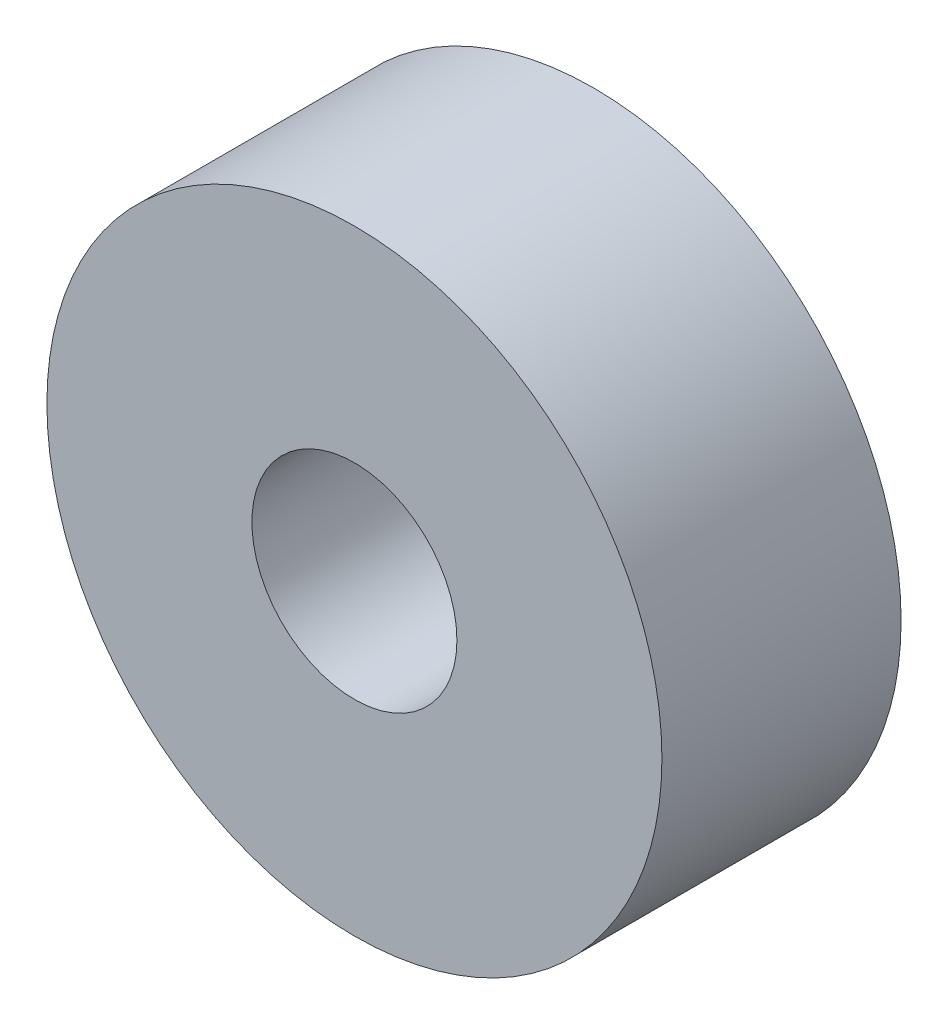
from build123d import *

# Parameters (mm, degrees)
SKETCH_1_R      = 9
SKETCH_1_R_2    = 3
EXTRUDE_1_DEPTH = 7


with BuildPart() as part:
    # 草图1 → 凸台-拉伸1 (new body)
    with BuildSketch(Plane.XY):
        Circle(SKETCH_1_R)
        Circle(SKETCH_1_R_2, mode=Mode.SUBTRACT)
    extrude(amount=EXTRUDE_1_DEPTH)


solid = part.part
